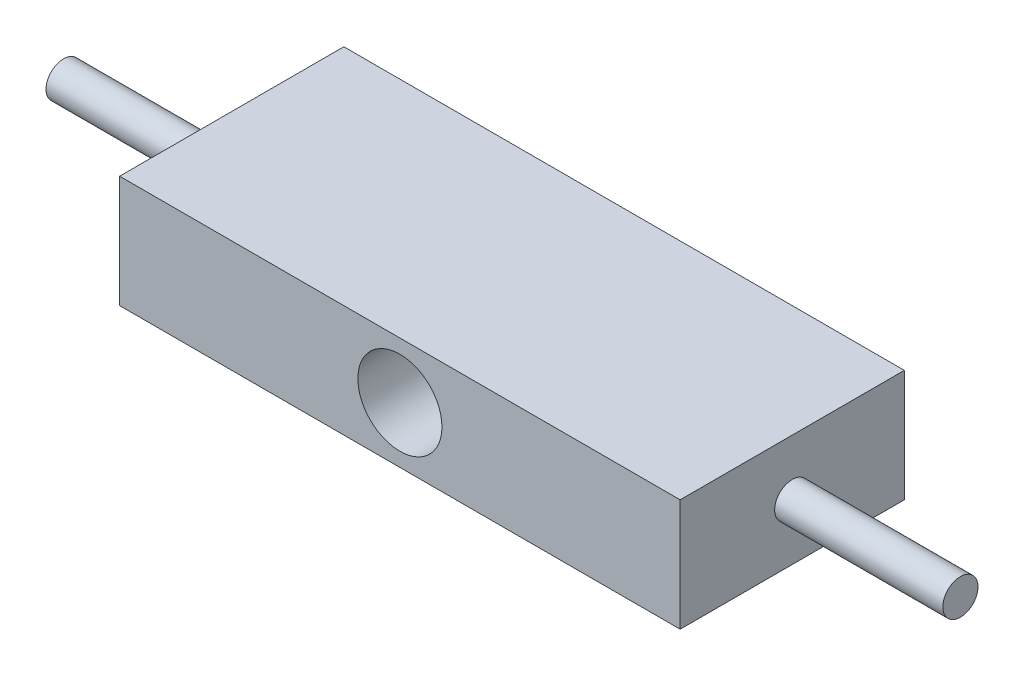
from build123d import *

# Parameters (mm, degrees)
SKETCH1_W           = 63.5
SKETCH1_H           = 12.7
SKETCH1_R           = 4.7625
BOSS_EXTRUDE1_DEPTH = 25.4
SKETCH2_R           = 1.9939
BOSS_EXTRUDE2_DEPTH = 19.05
SKETCH3_R           = 1.9939
BOSS_EXTRUDE3_DEPTH = 19.05


with BuildPart() as part:
    # Sketch1 → Boss-Extrude1 (new body)
    with BuildSketch(Plane.XY):
        Rectangle(SKETCH1_W, SKETCH1_H)
        Circle(SKETCH1_R, mode=Mode.SUBTRACT)
    extrude(amount=-BOSS_EXTRUDE1_DEPTH)

    # Sketch2 → Boss-Extrude2 (add)
    with BuildSketch(Plane(origin=(31.75, 0, 0), x_dir=(0, 0, -1), z_dir=(1, 0, 0))):
        with Locations((12.7, 0)):
            Circle(SKETCH2_R)
    extrude(amount=BOSS_EXTRUDE2_DEPTH)

    # Sketch3 → Boss-Extrude3 (add)
    with BuildSketch(Plane.ZY.offset(31.75)):
        with Locations((-12.7, 0)):
            Circle(SKETCH3_R)
    extrude(amount=BOSS_EXTRUDE3_DEPTH)


solid = part.part
